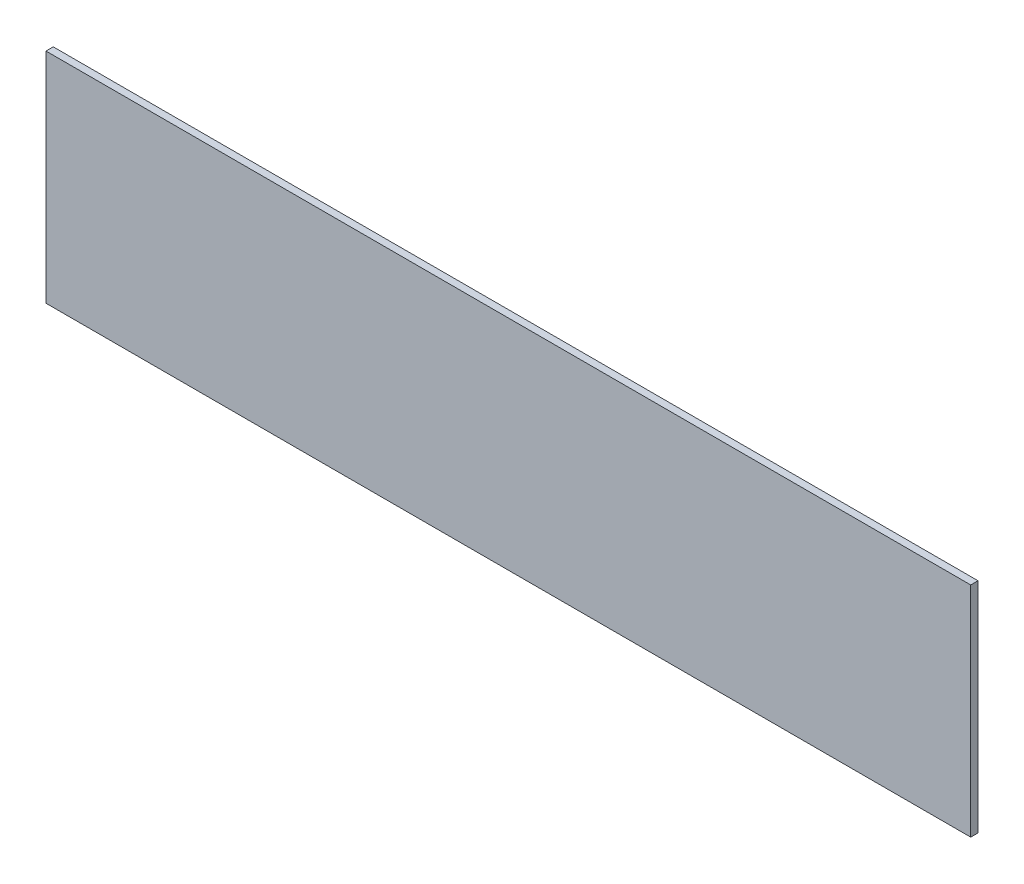
from build123d import *

# Parameters (mm, degrees)
SKETCH1_W           = 190.5
SKETCH1_H           = 45
BOSS_EXTRUDE1_DEPTH = 1.5


with BuildPart() as part:
    # Sketch1 → Boss-Extrude1 (new body)
    with BuildSketch(Plane.XY):
        Rectangle(SKETCH1_W, SKETCH1_H)
    extrude(amount=BOSS_EXTRUDE1_DEPTH)


solid = part.part
